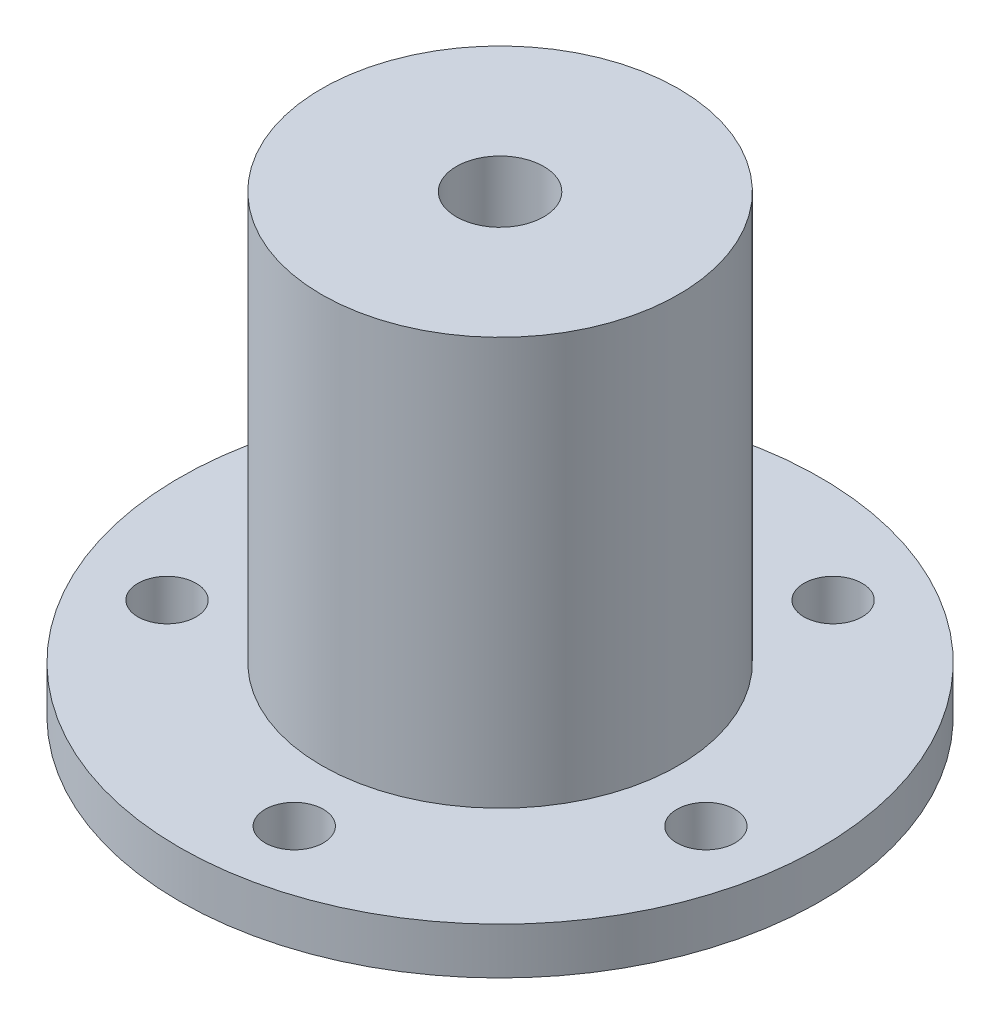
from build123d import *

# Parameters (mm, degrees)
SKIZZE1_R                       = 11
AUFSATZ_LINEAR_AUSTRAGEN1_DEPTH = 1.6
SKIZZE2_R                       = 6.125
AUFSATZ_LINEAR_AUSTRAGEN2_DEPTH = 14
SKIZZE3_R                       = 1.5
SCHNITT_LINEAR_AUSTRAGEN1_DEPTH = 16.6
SKIZZE5_R                       = 0.830846671
SCHNITT_LINEAR_AUSTRAGEN3_DEPTH = 12
SKIZZE8_R                       = 1
SCHNITT_LINEAR_AUSTRAGEN4_DEPTH = 1.6
SKIZZE7_R                       = 1.5
SCHNITT_LINEAR_AUSTRAGEN5_DEPTH = 10


with BuildPart() as part:
    # Skizze1 → Aufsatz-Linear austragen1 (new body)
    with BuildSketch(Plane(origin=(0, 0, 0), x_dir=(1, 0, 0), z_dir=(0, 1, 0))):
        Circle(SKIZZE1_R)
    extrude(amount=AUFSATZ_LINEAR_AUSTRAGEN1_DEPTH)

    # Skizze2 → Aufsatz-Linear austragen2 (add)
    with BuildSketch(Plane(origin=(0, 1.6, 0), x_dir=(1, 0, 0), z_dir=(0, 1, 0))):
        Circle(SKIZZE2_R)
    extrude(amount=AUFSATZ_LINEAR_AUSTRAGEN2_DEPTH)

    # Skizze3 → Schnitt-Linear austragen1 (cut, through all)
    with BuildSketch(Plane(origin=(0, 15.6, 0), x_dir=(1, 0, 0), z_dir=(0, 1, 0))):
        Circle(SKIZZE3_R)
    extrude(amount=-SCHNITT_LINEAR_AUSTRAGEN1_DEPTH, mode=Mode.SUBTRACT)

    # Skizze5 → Schnitt-Linear austragen3 (cut, through all)
    with BuildSketch(Plane.XY):
        with Locations((0, 10.6)):
            Circle(SKIZZE5_R)
    extrude(amount=-SCHNITT_LINEAR_AUSTRAGEN3_DEPTH, mode=Mode.SUBTRACT)

    # Skizze8 → Schnitt-Linear austragen4 (cut)
    with BuildSketch(Plane.XZ):
        with Locations((-6.01040764, -6.01040764)):
            Circle(SKIZZE8_R)
        with Locations((-7.573555456, 3.858919248)):
            Circle(SKIZZE8_R)
        with Locations((1.329692953, 8.395350895)):
            Circle(SKIZZE8_R)
        with Locations((8.395350895, 1.329692953)):
            Circle(SKIZZE8_R)
        with Locations((3.858919248, -7.573555456)):
            Circle(SKIZZE8_R)
    extrude(amount=-SCHNITT_LINEAR_AUSTRAGEN4_DEPTH, mode=Mode.SUBTRACT)

    # Skizze7 → Schnitt-Linear austragen5 (cut)
    with BuildSketch(Plane.XY):
        with Locations((0, 10.6)):
            Circle(SKIZZE7_R)
    extrude(amount=-SCHNITT_LINEAR_AUSTRAGEN5_DEPTH, mode=Mode.SUBTRACT)


solid = part.part
